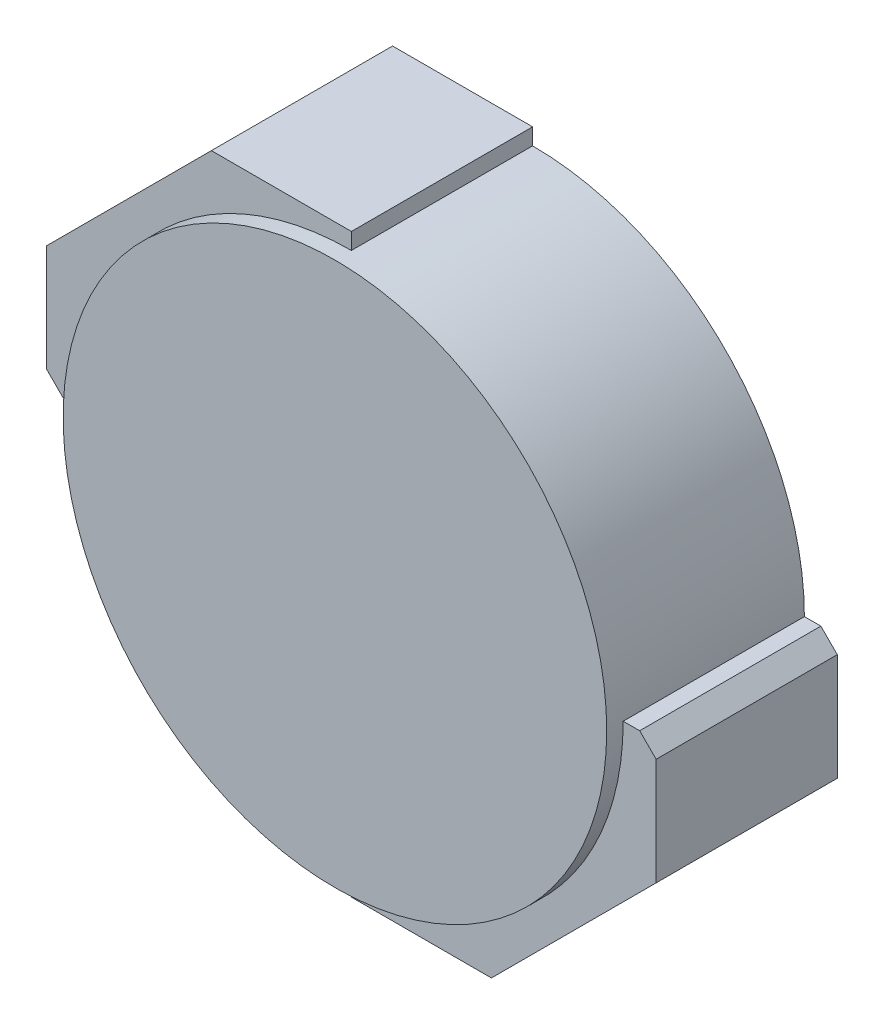
from build123d import *

# Parameters (mm, degrees)
SKETCH1_R           = 1.65
BOSS_EXTRUDE1_DEPTH = 1.2
SKETCH2_W           = 1.85
SKETCH2_H           = 1.75
BOSS_EXTRUDE2_DEPTH = 1.1
CHAMFER1_SIZE       = 0.1
CHAMFER2_SIZE       = 1


with BuildPart() as part:
    # Sketch1 → Boss-Extrude1 (new body)
    with BuildSketch(Plane.XY):
        Circle(SKETCH1_R)
    extrude(amount=BOSS_EXTRUDE1_DEPTH)

    # Sketch2 → Boss-Extrude2 (add)
    with BuildSketch(Plane.XY):
        with Locations((-0.925, 0.875)):
            Rectangle(SKETCH2_W, SKETCH2_H)
        with Locations((0.925, -0.875)):
            Rectangle(SKETCH2_W, SKETCH2_H)
    extrude(amount=BOSS_EXTRUDE2_DEPTH)

    # Chamfer1
    chamfer1_edges = [part.edges().sort_by_distance(p)[0] for p in [
        (1.85, 0, 0.55),
        (-1.85, 0, 0.55),
    ]]
    chamfer(chamfer1_edges, length=CHAMFER1_SIZE)

    # Chamfer2
    chamfer2_edges = [part.edges().sort_by_distance(p)[0] for p in [
        (-1.85, 1.75, 0.55),
        (1.85, -1.75, 0.55),
    ]]
    chamfer(chamfer2_edges, length=CHAMFER2_SIZE)


solid = part.part
